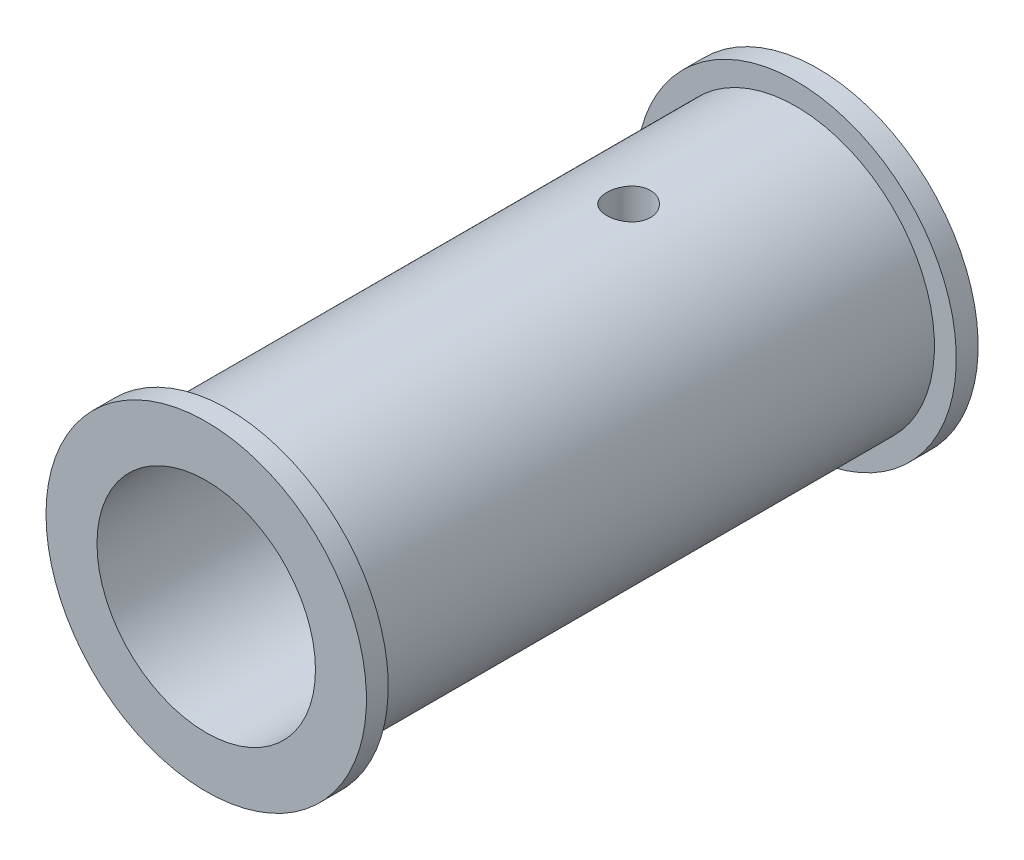
from build123d import *

# Parameters (mm, degrees)
CORTAR_EXTRUIR1_DEPTH = 35
CROQUIS3_W            = 5.6
CROQUIS3_H            = 2.5
CORTAR_EXTRUIR2_DEPTH = 35
CROQUIS4_R            = 1.5
CORTAR_EXTRUIR3_DEPTH = 12


with BuildPart() as part:
    # Croquis1 → Revolución1 (revolve)
    with BuildSketch(Plane(origin=(0, 0, 0), x_dir=(0, 0, -1), z_dir=(1, 0, 0))):
        Polygon((-24, 7.5), (-24, 11), (-22.5, 11), (-22.5, 9.5), (16.5, 9.5), (16.5, 11), (18, 11), (18, 8), (10, 8), (10, 0), (0, 0), (0, 7.5), align=None)
    revolve(axis=Axis((0, 0, 0), (0, 0, 1)))

    # Croquis2 → Cortar-Extruir1 (cut, through all)
    with BuildSketch(Plane(origin=(0, 0, -10), x_dir=(-1, 0, 0), z_dir=(0, 0, -1))):
        with BuildLine():
            Line((-1.17260394, 1.125), (1.17260394, 1.125))
            ThreePointArc((1.17260394, 1.125), (0, -1.625), (-1.17260394, 1.125))
        make_face()
    extrude(amount=-CORTAR_EXTRUIR1_DEPTH, mode=Mode.SUBTRACT)

    # Croquis3 → Cortar-Extruir2 (cut, through all)
    with BuildSketch(Plane(origin=(0, 0, -10), x_dir=(-1, 0, 0), z_dir=(0, 0, -1))):
        with Locations((0, 3.375)):
            Rectangle(CROQUIS3_W, CROQUIS3_H)
    extrude(amount=-CORTAR_EXTRUIR2_DEPTH, mode=Mode.SUBTRACT)

    # Croquis4 → Cortar-Extruir3 (cut, through all)
    with BuildSketch(Plane(origin=(0, 0, 0), x_dir=(1, 0, 0), z_dir=(0, 1, 0))):
        with Locations((0, 5)):
            Circle(CROQUIS4_R)
    extrude(amount=CORTAR_EXTRUIR3_DEPTH, mode=Mode.SUBTRACT)


solid = part.part
